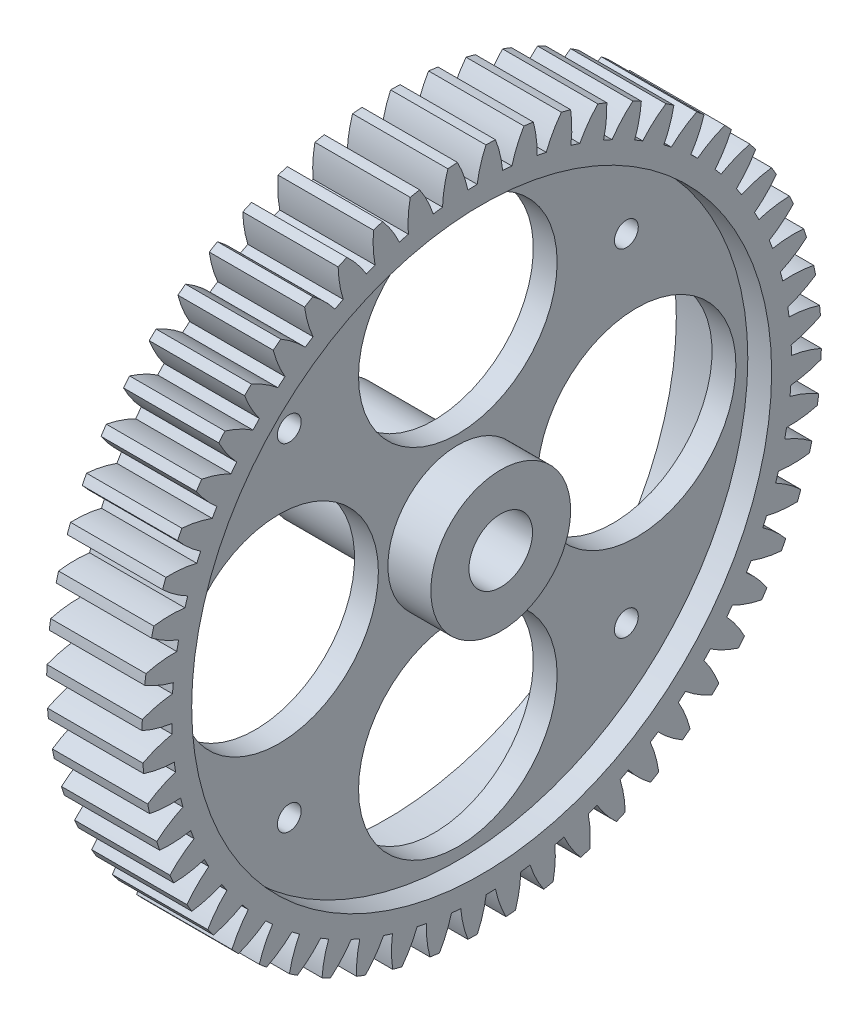
from build123d import *

# Parameters (mm, degrees)
SKETCH1_R           = 39
SKETCH1_R_2         = 4
SKETCH1_R_3         = 12.5
SKETCH1_R_4         = 1.5
BOSS_EXTRUDE1_DEPTH = 12
SKETCH4_R           = 36.5
CUT_EXTRUDE1_DEPTH  = 3
SKETCH5_R           = 36.5
CUT_EXTRUDE2_DEPTH  = 6
SKETCH6_R           = 8.8
SKETCH6_R_2         = 4
BOSS_EXTRUDE2_DEPTH = 5.4
SKETCH7_R           = 7.2
SKETCH7_R_2         = 4
BOSS_EXTRUDE3_DEPTH = 13.5


with BuildPart() as part:
    # Sketch1 → Boss-Extrude1 (new body)
    with BuildSketch(Plane(origin=(0, 0, 0), x_dir=(0, 0, -1), z_dir=(1, 0, 0))):
        Circle(SKETCH1_R)
        Circle(SKETCH1_R_2, mode=Mode.SUBTRACT)
        with Locations((0, 22.5)):
            Circle(SKETCH1_R_3, mode=Mode.SUBTRACT)
        with Locations((22.5, 0)):
            Circle(SKETCH1_R_3, mode=Mode.SUBTRACT)
        with Locations((0, -22.5)):
            Circle(SKETCH1_R_3, mode=Mode.SUBTRACT)
        with Locations((-22.5, 0)):
            Circle(SKETCH1_R_3, mode=Mode.SUBTRACT)
        with Locations((21.213203436, -21.213203436)):
            Circle(SKETCH1_R_4, mode=Mode.SUBTRACT)
        with Locations((-21.213203436, -21.213203436)):
            Circle(SKETCH1_R_4, mode=Mode.SUBTRACT)
        with Locations((-21.213203436, 21.213203436)):
            Circle(SKETCH1_R_4, mode=Mode.SUBTRACT)
        with Locations((21.213203436, 21.213203436)):
            Circle(SKETCH1_R_4, mode=Mode.SUBTRACT)
        with BuildLine():
            ThreePointArc((-0.563449374, 38.995929593), (1.036858006, 38.986214557), (2.635419512, 38.910854064))
            ThreePointArc((2.635419512, 38.910854064), (2.319554532, 40.844402901), (1.736231861, 42.714728127))
            ThreePointArc((1.736231861, 42.714728127), (1.136555891, 42.734889034), (0.536656028, 42.74663145))
            ThreePointArc((0.536656028, 42.74663145), (-0.145256199, 40.909955783), (-0.563449374, 38.995929593))
        make_face()
        with BuildLine():
            ThreePointArc((5.319385843, 42.417763192), (4.436118908, 40.668986102), (3.806252304, 38.813817686))
            ThreePointArc((3.806252304, 38.813817686), (5.395409549, 38.624986159), (6.975481938, 38.371117416))
            ThreePointArc((6.975481938, 38.371117416), (6.878091832, 40.32787416), (6.507846956, 42.251750591))
            ThreePointArc((6.507846956, 42.251750591), (5.914198928, 42.338927136), (5.319385843, 42.417763192))
        make_face()
        with BuildLine():
            ThreePointArc((10.035221295, 41.555466952), (8.961707246, 39.916580324), (8.128088151, 38.143599502))
            ThreePointArc((8.128088151, 38.143599502), (9.686110686, 37.77802615), (11.22782363, 37.348841703))
            ThreePointArc((11.22782363, 37.348841703), (11.350133137, 39.304199003), (11.197622099, 41.257432777))
            ThreePointArc((11.197622099, 41.257432777), (10.617467482, 41.410528664), (10.035221295, 41.555466952))
        make_face()
        with BuildLine():
            ThreePointArc((14.624858016, 40.170586603), (13.374596916, 38.662200388), (12.347708574, 36.993703423))
            ThreePointArc((12.347708574, 36.993703423), (13.855003361, 36.455985542), (15.338968926, 35.856882635))
            ThreePointArc((15.338968926, 35.856882635), (15.679439933, 37.786250739), (15.746580648, 39.744278807))
            ThreePointArc((15.746580648, 39.744278807), (15.187215222, 39.961368768), (14.624858016, 40.170586603))
        make_face()
        with BuildLine():
            ThreePointArc((19.030578662, 38.28053782), (17.619293269, 36.921620851), (16.412049397, 35.378590059))
            ThreePointArc((16.412049397, 35.378590059), (17.84966133, 34.675489765), (19.257217788, 33.914002463))
            ThreePointArc((19.257217788, 33.914002463), (19.811568673, 35.793118448), (20.097516809, 37.731317471))
            ThreePointArc((20.097516809, 37.731317471), (19.565974919, 38.009671473), (19.030578662, 38.28053782))
        make_face()
        with BuildLine():
            ThreePointArc((23.19697874, 35.909089063), (21.642416787, 34.716730508), (20.269999177, 33.318570398))
            ThreePointArc((20.269999177, 33.318570398), (21.619849451, 32.458929584), (22.933295963, 31.544634033))
            ThreePointArc((22.933295963, 31.544634033), (23.694555443, 33.349866925), (24.195715035, 35.243862926))
            ThreePointArc((24.195715035, 35.243862926), (23.698681129, 35.579980505), (23.19697874, 35.909089063))
        make_face()
        with BuildLine():
            ThreePointArc((27.071663351, 33.086062676), (25.393374356, 32.075257136), (23.873041955, 30.839550382))
            ThreePointArc((23.873041955, 30.839550382), (25.118155421, 29.83417953), (26.320974635, 28.778573527))
            ThreePointArc((26.320974635, 28.778573527), (27.27956943, 30.487221475), (27.989638105, 32.313196356))
            ThreePointArc((27.989638105, 32.313196356), (27.533362673, 32.702850639), (27.071663351, 33.086062676))
        make_face()
        with BuildLine():
            ThreePointArc((30.605906088, 29.846959855), (28.824995509, 29.030418795), (27.17586738, 27.972705127))
            ThreePointArc((27.17586738, 27.972705127), (28.300586013, 26.834247359), (29.377651779, 25.650605762))
            ThreePointArc((29.377651779, 25.650605762), (30.521527004, 27.241181526), (31.431575237, 28.976172593))
            ThreePointArc((31.431575237, 28.976172593), (31.021796207, 29.414463451), (30.605906088, 29.846959855))
        make_face()
        with BuildLine():
            ThreePointArc((33.755261797, 26.232514195), (31.894125619, 25.620506094), (30.136940505, 24.754086875))
            ThreePointArc((30.136940505, 24.754086875), (31.127120316, 23.496858957), (32.064887907, 22.200066746))
            ThreePointArc((32.064887907, 22.200066746), (33.379658666, 23.652567913), (34.478242073, 25.274756647))
            ThreePointArc((34.478242073, 25.274756647), (34.120112654, 25.756172319), (33.755261797, 26.232514195))
        make_face()
        with BuildLine():
            ThreePointArc((36.480125505, 22.288179449), (34.562168594, 21.888400664), (32.719024117, 21.224171617))
            ThreePointArc((32.719024117, 21.224171617), (33.56221302, 19.863983921), (34.348889464, 18.47034901))
            ThreePointArc((34.348889464, 18.47034901), (35.818021753, 19.766509536), (37.09132501, 21.255495971))
            ThreePointArc((37.09132501, 21.255495971), (36.789348887, 21.773982375), (36.480125505, 22.288179449))
        make_face()
        with BuildLine():
            ThreePointArc((38.746230468, 18.063557914), (36.795572245, 17.881035895), (34.889647017, 17.427350087))
            ThreePointArc((34.889647017, 17.427350087), (35.575241422, 15.981307762), (36.200933807, 14.508355919))
            ThreePointArc((36.200933807, 14.508355919), (37.805952435, 15.631875832), (39.237963015, 16.968935101))
            ThreePointArc((39.237963015, 16.968935101), (38.995937712, 17.51797197), (38.746230468, 18.063557914))
        make_face()
        with BuildLine():
            ThreePointArc((40.525079102, 13.611776658), (38.566250226, 13.648806725), (36.621512362, 13.411369518))
            ThreePointArc((36.621512362, 13.411369518), (37.140890522, 11.897657385), (37.597730404, 10.363911834))
            ThreePointArc((37.597730404, 10.363911834), (39.318451329, 11.30066222), (40.891160868, 12.468980027))
            ThreePointArc((40.891160868, 12.468980027), (40.712129995, 13.041662903), (40.525079102, 13.611776658))
        make_face()
        with BuildLine():
            ThreePointArc((41.794301353, 8.988819413), (39.851935234, 9.244935892), (37.89284094, 9.226733196))
            ThreePointArc((37.89284094, 9.226733196), (38.239471374, 7.664387064), (38.521713725, 6.089135544))
            ThreePointArc((38.521713725, 6.089135544), (40.336497885, 6.827336223), (42.030128647, 7.812220294))
            ThreePointArc((42.030128647, 7.812220294), (41.916343621, 8.401347358), (41.794301353, 8.988819413))
        make_face()
        with BuildLine():
            ThreePointArc((42.537936015, 4.252822548), (40.636459034, 4.724804625), (38.687645058, 4.92606535))
            ThreePointArc((38.687645058, 4.92606535), (38.857168686, 3.334732628), (38.961264146, 1.737784842))
            ThreePointArc((38.961264146, 1.737784842), (40.847289576, 2.268152513), (42.640543172, 3.057217358))
            ThreePointArc((42.640543172, 3.057217358), (42.593434906, 3.655379996), (42.537936015, 4.252822548))
        make_face()
        with BuildLine():
            ThreePointArc((42.74663145, -0.536656028), (40.909955783, 0.145256199), (38.995929593, 0.563449374))
            ThreePointArc((38.995929593, 0.563449374), (38.986214557, -1.036858006), (38.910854064, -2.635419512))
            ThreePointArc((38.910854064, -2.635419512), (40.844402901, -2.319554532), (42.714728127, -1.736231861))
            ThreePointArc((42.714728127, -1.736231861), (42.734889034, -1.136555891), (42.74663145, -0.536656028))
        make_face()
        with BuildLine():
            ThreePointArc((42.417763192, -5.319385843), (40.668986102, -4.436118908), (38.813817686, -3.806252304))
            ThreePointArc((38.813817686, -3.806252304), (38.624986159, -5.395409549), (38.371117416, -6.975481938))
            ThreePointArc((38.371117416, -6.975481938), (40.32787416, -6.878091832), (42.251750591, -6.507846956))
            ThreePointArc((42.251750591, -6.507846956), (42.338927136, -5.914198928), (42.417763192, -5.319385843))
        make_face()
        with BuildLine():
            ThreePointArc((41.555466952, -10.035221295), (39.916580324, -8.961707246), (38.143599502, -8.128088151))
            ThreePointArc((38.143599502, -8.128088151), (37.77802615, -9.686110686), (37.348841703, -11.22782363))
            ThreePointArc((37.348841703, -11.22782363), (39.304199003, -11.350133137), (41.257432777, -11.197622099))
            ThreePointArc((41.257432777, -11.197622099), (41.410528664, -10.617467482), (41.555466952, -10.035221295))
        make_face()
        with BuildLine():
            ThreePointArc((40.170586603, -14.624858016), (38.662200388, -13.374596916), (36.993703423, -12.347708574))
            ThreePointArc((36.993703423, -12.347708574), (36.455985542, -13.855003361), (35.856882635, -15.338968926))
            ThreePointArc((35.856882635, -15.338968926), (37.786250739, -15.679439933), (39.744278807, -15.746580648))
            ThreePointArc((39.744278807, -15.746580648), (39.961368768, -15.187215222), (40.170586603, -14.624858016))
        make_face()
        with BuildLine():
            ThreePointArc((38.28053782, -19.030578662), (36.921620851, -17.619293269), (35.378590059, -16.412049397))
            ThreePointArc((35.378590059, -16.412049397), (34.675489765, -17.84966133), (33.914002463, -19.257217788))
            ThreePointArc((33.914002463, -19.257217788), (35.793118448, -19.811568673), (37.731317471, -20.097516809))
            ThreePointArc((37.731317471, -20.097516809), (38.009671473, -19.565974919), (38.28053782, -19.030578662))
        make_face()
        with BuildLine():
            ThreePointArc((35.909089063, -23.19697874), (34.716730508, -21.642416787), (33.318570398, -20.269999177))
            ThreePointArc((33.318570398, -20.269999177), (32.458929584, -21.619849451), (31.544634033, -22.933295963))
            ThreePointArc((31.544634033, -22.933295963), (33.349866925, -23.694555443), (35.243862926, -24.195715035))
            ThreePointArc((35.243862926, -24.195715035), (35.579980505, -23.698681129), (35.909089063, -23.19697874))
        make_face()
        with BuildLine():
            ThreePointArc((33.086062676, -27.071663351), (32.075257136, -25.393374356), (30.839550382, -23.873041955))
            ThreePointArc((30.839550382, -23.873041955), (29.83417953, -25.118155421), (28.778573527, -26.320974635))
            ThreePointArc((28.778573527, -26.320974635), (30.487221475, -27.27956943), (32.313196356, -27.989638105))
            ThreePointArc((32.313196356, -27.989638105), (32.702850639, -27.533362673), (33.086062676, -27.071663351))
        make_face()
        with BuildLine():
            ThreePointArc((29.846959855, -30.605906088), (29.030418795, -28.824995509), (27.972705127, -27.17586738))
            ThreePointArc((27.972705127, -27.17586738), (26.834247359, -28.300586013), (25.650605762, -29.377651779))
            ThreePointArc((25.650605762, -29.377651779), (27.241181526, -30.521527004), (28.976172593, -31.431575237))
            ThreePointArc((28.976172593, -31.431575237), (29.414463451, -31.021796207), (29.846959855, -30.605906088))
        make_face()
        with BuildLine():
            ThreePointArc((26.232514195, -33.755261797), (25.620506094, -31.894125619), (24.754086875, -30.136940505))
            ThreePointArc((24.754086875, -30.136940505), (23.496858957, -31.127120316), (22.200066746, -32.064887907))
            ThreePointArc((22.200066746, -32.064887907), (23.652567913, -33.379658666), (25.274756647, -34.478242073))
            ThreePointArc((25.274756647, -34.478242073), (25.756172319, -34.120112654), (26.232514195, -33.755261797))
        make_face()
        with BuildLine():
            ThreePointArc((22.288179449, -36.480125505), (21.888400664, -34.562168594), (21.224171617, -32.719024117))
            ThreePointArc((21.224171617, -32.719024117), (19.863983921, -33.56221302), (18.47034901, -34.348889464))
            ThreePointArc((18.47034901, -34.348889464), (19.766509536, -35.818021753), (21.255495971, -37.09132501))
            ThreePointArc((21.255495971, -37.09132501), (21.773982375, -36.789348887), (22.288179449, -36.480125505))
        make_face()
        with BuildLine():
            ThreePointArc((18.063557914, -38.746230468), (17.881035895, -36.795572245), (17.427350087, -34.889647017))
            ThreePointArc((17.427350087, -34.889647017), (15.981307762, -35.575241422), (14.508355919, -36.200933807))
            ThreePointArc((14.508355919, -36.200933807), (15.631875832, -37.805952435), (16.968935101, -39.237963015))
            ThreePointArc((16.968935101, -39.237963015), (17.51797197, -38.995937712), (18.063557914, -38.746230468))
        make_face()
        with BuildLine():
            ThreePointArc((13.611776658, -40.525079102), (13.648806725, -38.566250226), (13.411369518, -36.621512362))
            ThreePointArc((13.411369518, -36.621512362), (11.897657385, -37.140890522), (10.363911834, -37.597730404))
            ThreePointArc((10.363911834, -37.597730404), (11.30066222, -39.318451329), (12.468980027, -40.891160868))
            ThreePointArc((12.468980027, -40.891160868), (13.041662903, -40.712129995), (13.611776658, -40.525079102))
        make_face()
        with BuildLine():
            ThreePointArc((8.988819413, -41.794301353), (9.244935892, -39.851935234), (9.226733196, -37.89284094))
            ThreePointArc((9.226733196, -37.89284094), (7.664387064, -38.239471374), (6.089135544, -38.521713725))
            ThreePointArc((6.089135544, -38.521713725), (6.827336223, -40.336497885), (7.812220294, -42.030128647))
            ThreePointArc((7.812220294, -42.030128647), (8.401347358, -41.916343621), (8.988819413, -41.794301353))
        make_face()
        with BuildLine():
            ThreePointArc((4.252822548, -42.537936015), (4.724804625, -40.636459034), (4.92606535, -38.687645058))
            ThreePointArc((4.92606535, -38.687645058), (3.334732628, -38.857168686), (1.737784842, -38.961264146))
            ThreePointArc((1.737784842, -38.961264146), (2.268152513, -40.847289576), (3.057217358, -42.640543172))
            ThreePointArc((3.057217358, -42.640543172), (3.655379996, -42.593434906), (4.252822548, -42.537936015))
        make_face()
        with BuildLine():
            ThreePointArc((-0.536656028, -42.74663145), (0.145256199, -40.909955783), (0.563449374, -38.995929593))
            ThreePointArc((0.563449374, -38.995929593), (-1.036858006, -38.986214557), (-2.635419512, -38.910854064))
            ThreePointArc((-2.635419512, -38.910854064), (-2.319554532, -40.844402901), (-1.736231861, -42.714728127))
            ThreePointArc((-1.736231861, -42.714728127), (-1.136555891, -42.734889034), (-0.536656028, -42.74663145))
        make_face()
        with BuildLine():
            ThreePointArc((-5.319385843, -42.417763192), (-4.436118908, -40.668986102), (-3.806252304, -38.813817686))
            ThreePointArc((-3.806252304, -38.813817686), (-5.395409549, -38.624986159), (-6.975481938, -38.371117416))
            ThreePointArc((-6.975481938, -38.371117416), (-6.878091832, -40.32787416), (-6.507846956, -42.251750591))
            ThreePointArc((-6.507846956, -42.251750591), (-5.914198928, -42.338927136), (-5.319385843, -42.417763192))
        make_face()
        with BuildLine():
            ThreePointArc((-10.035221295, -41.555466952), (-8.961707246, -39.916580324), (-8.128088151, -38.143599502))
            ThreePointArc((-8.128088151, -38.143599502), (-9.686110686, -37.77802615), (-11.22782363, -37.348841703))
            ThreePointArc((-11.22782363, -37.348841703), (-11.350133137, -39.304199003), (-11.197622099, -41.257432777))
            ThreePointArc((-11.197622099, -41.257432777), (-10.617467482, -41.410528664), (-10.035221295, -41.555466952))
        make_face()
        with BuildLine():
            ThreePointArc((-14.624858016, -40.170586603), (-13.374596916, -38.662200388), (-12.347708574, -36.993703423))
            ThreePointArc((-12.347708574, -36.993703423), (-13.855003361, -36.455985542), (-15.338968926, -35.856882635))
            ThreePointArc((-15.338968926, -35.856882635), (-15.679439933, -37.786250739), (-15.746580648, -39.744278807))
            ThreePointArc((-15.746580648, -39.744278807), (-15.187215222, -39.961368768), (-14.624858016, -40.170586603))
        make_face()
        with BuildLine():
            ThreePointArc((-19.030578662, -38.28053782), (-17.619293269, -36.921620851), (-16.412049397, -35.378590059))
            ThreePointArc((-16.412049397, -35.378590059), (-17.84966133, -34.675489765), (-19.257217788, -33.914002463))
            ThreePointArc((-19.257217788, -33.914002463), (-19.811568673, -35.793118448), (-20.097516809, -37.731317471))
            ThreePointArc((-20.097516809, -37.731317471), (-19.565974919, -38.009671473), (-19.030578662, -38.28053782))
        make_face()
        with BuildLine():
            ThreePointArc((-23.19697874, -35.909089063), (-21.642416787, -34.716730508), (-20.269999177, -33.318570398))
            ThreePointArc((-20.269999177, -33.318570398), (-21.619849451, -32.458929584), (-22.933295963, -31.544634033))
            ThreePointArc((-22.933295963, -31.544634033), (-23.694555443, -33.349866925), (-24.195715035, -35.243862926))
            ThreePointArc((-24.195715035, -35.243862926), (-23.698681129, -35.579980505), (-23.19697874, -35.909089063))
        make_face()
        with BuildLine():
            ThreePointArc((-27.071663351, -33.086062676), (-25.393374356, -32.075257136), (-23.873041955, -30.839550382))
            ThreePointArc((-23.873041955, -30.839550382), (-25.118155421, -29.83417953), (-26.320974635, -28.778573527))
            ThreePointArc((-26.320974635, -28.778573527), (-27.27956943, -30.487221475), (-27.989638105, -32.313196356))
            ThreePointArc((-27.989638105, -32.313196356), (-27.533362673, -32.702850639), (-27.071663351, -33.086062676))
        make_face()
        with BuildLine():
            ThreePointArc((-30.605906088, -29.846959855), (-28.824995509, -29.030418795), (-27.17586738, -27.972705127))
            ThreePointArc((-27.17586738, -27.972705127), (-28.300586013, -26.834247359), (-29.377651779, -25.650605762))
            ThreePointArc((-29.377651779, -25.650605762), (-30.521527004, -27.241181526), (-31.431575237, -28.976172593))
            ThreePointArc((-31.431575237, -28.976172593), (-31.021796207, -29.414463451), (-30.605906088, -29.846959855))
        make_face()
        with BuildLine():
            ThreePointArc((-33.755261797, -26.232514195), (-31.894125619, -25.620506094), (-30.136940505, -24.754086875))
            ThreePointArc((-30.136940505, -24.754086875), (-31.127120316, -23.496858957), (-32.064887907, -22.200066746))
            ThreePointArc((-32.064887907, -22.200066746), (-33.379658666, -23.652567913), (-34.478242073, -25.274756647))
            ThreePointArc((-34.478242073, -25.274756647), (-34.120112654, -25.756172319), (-33.755261797, -26.232514195))
        make_face()
        with BuildLine():
            ThreePointArc((-36.480125505, -22.288179449), (-34.562168594, -21.888400664), (-32.719024117, -21.224171617))
            ThreePointArc((-32.719024117, -21.224171617), (-33.56221302, -19.863983921), (-34.348889464, -18.47034901))
            ThreePointArc((-34.348889464, -18.47034901), (-35.818021753, -19.766509536), (-37.09132501, -21.255495971))
            ThreePointArc((-37.09132501, -21.255495971), (-36.789348887, -21.773982375), (-36.480125505, -22.288179449))
        make_face()
        with BuildLine():
            ThreePointArc((-38.746230468, -18.063557914), (-36.795572245, -17.881035895), (-34.889647017, -17.427350087))
            ThreePointArc((-34.889647017, -17.427350087), (-35.575241422, -15.981307762), (-36.200933807, -14.508355919))
            ThreePointArc((-36.200933807, -14.508355919), (-37.805952435, -15.631875832), (-39.237963015, -16.968935101))
            ThreePointArc((-39.237963015, -16.968935101), (-38.995937712, -17.51797197), (-38.746230468, -18.063557914))
        make_face()
        with BuildLine():
            ThreePointArc((-40.525079102, -13.611776658), (-38.566250226, -13.648806725), (-36.621512362, -13.411369518))
            ThreePointArc((-36.621512362, -13.411369518), (-37.140890522, -11.897657385), (-37.597730404, -10.363911834))
            ThreePointArc((-37.597730404, -10.363911834), (-39.318451329, -11.30066222), (-40.891160868, -12.468980027))
            ThreePointArc((-40.891160868, -12.468980027), (-40.712129995, -13.041662903), (-40.525079102, -13.611776658))
        make_face()
        with BuildLine():
            ThreePointArc((-41.794301353, -8.988819413), (-39.851935234, -9.244935892), (-37.89284094, -9.226733196))
            ThreePointArc((-37.89284094, -9.226733196), (-38.239471374, -7.664387064), (-38.521713725, -6.089135544))
            ThreePointArc((-38.521713725, -6.089135544), (-40.336497885, -6.827336223), (-42.030128647, -7.812220294))
            ThreePointArc((-42.030128647, -7.812220294), (-41.916343621, -8.401347358), (-41.794301353, -8.988819413))
        make_face()
        with BuildLine():
            ThreePointArc((-42.537936015, -4.252822548), (-40.636459034, -4.724804625), (-38.687645058, -4.92606535))
            ThreePointArc((-38.687645058, -4.92606535), (-38.857168686, -3.334732628), (-38.961264146, -1.737784842))
            ThreePointArc((-38.961264146, -1.737784842), (-40.847289576, -2.268152513), (-42.640543172, -3.057217358))
            ThreePointArc((-42.640543172, -3.057217358), (-42.593434906, -3.655379996), (-42.537936015, -4.252822548))
        make_face()
        with BuildLine():
            ThreePointArc((-42.74663145, 0.536656028), (-40.909955783, -0.145256199), (-38.995929593, -0.563449374))
            ThreePointArc((-38.995929593, -0.563449374), (-38.986214557, 1.036858006), (-38.910854064, 2.635419512))
            ThreePointArc((-38.910854064, 2.635419512), (-40.844402901, 2.319554532), (-42.714728127, 1.736231861))
            ThreePointArc((-42.714728127, 1.736231861), (-42.734889034, 1.136555891), (-42.74663145, 0.536656028))
        make_face()
        with BuildLine():
            ThreePointArc((-42.417763192, 5.319385843), (-40.668986102, 4.436118908), (-38.813817686, 3.806252304))
            ThreePointArc((-38.813817686, 3.806252304), (-38.624986159, 5.395409549), (-38.371117416, 6.975481938))
            ThreePointArc((-38.371117416, 6.975481938), (-40.32787416, 6.878091832), (-42.251750591, 6.507846956))
            ThreePointArc((-42.251750591, 6.507846956), (-42.338927136, 5.914198928), (-42.417763192, 5.319385843))
        make_face()
        with BuildLine():
            ThreePointArc((-41.555466952, 10.035221295), (-39.916580324, 8.961707246), (-38.143599502, 8.128088151))
            ThreePointArc((-38.143599502, 8.128088151), (-37.77802615, 9.686110686), (-37.348841703, 11.22782363))
            ThreePointArc((-37.348841703, 11.22782363), (-39.304199003, 11.350133137), (-41.257432777, 11.197622099))
            ThreePointArc((-41.257432777, 11.197622099), (-41.410528664, 10.617467482), (-41.555466952, 10.035221295))
        make_face()
        with BuildLine():
            ThreePointArc((-40.170586603, 14.624858016), (-38.662200388, 13.374596916), (-36.993703423, 12.347708574))
            ThreePointArc((-36.993703423, 12.347708574), (-36.455985542, 13.855003361), (-35.856882635, 15.338968926))
            ThreePointArc((-35.856882635, 15.338968926), (-37.786250739, 15.679439933), (-39.744278807, 15.746580648))
            ThreePointArc((-39.744278807, 15.746580648), (-39.961368768, 15.187215222), (-40.170586603, 14.624858016))
        make_face()
        with BuildLine():
            ThreePointArc((-38.28053782, 19.030578662), (-36.921620851, 17.619293269), (-35.378590059, 16.412049397))
            ThreePointArc((-35.378590059, 16.412049397), (-34.675489765, 17.84966133), (-33.914002463, 19.257217788))
            ThreePointArc((-33.914002463, 19.257217788), (-35.793118448, 19.811568673), (-37.731317471, 20.097516809))
            ThreePointArc((-37.731317471, 20.097516809), (-38.009671473, 19.565974919), (-38.28053782, 19.030578662))
        make_face()
        with BuildLine():
            ThreePointArc((-35.909089063, 23.19697874), (-34.716730508, 21.642416787), (-33.318570398, 20.269999177))
            ThreePointArc((-33.318570398, 20.269999177), (-32.458929584, 21.619849451), (-31.544634033, 22.933295963))
            ThreePointArc((-31.544634033, 22.933295963), (-33.349866925, 23.694555443), (-35.243862926, 24.195715035))
            ThreePointArc((-35.243862926, 24.195715035), (-35.579980505, 23.698681129), (-35.909089063, 23.19697874))
        make_face()
        with BuildLine():
            ThreePointArc((-33.086062676, 27.071663351), (-32.075257136, 25.393374356), (-30.839550382, 23.873041955))
            ThreePointArc((-30.839550382, 23.873041955), (-29.83417953, 25.118155421), (-28.778573527, 26.320974635))
            ThreePointArc((-28.778573527, 26.320974635), (-30.487221475, 27.27956943), (-32.313196356, 27.989638105))
            ThreePointArc((-32.313196356, 27.989638105), (-32.702850639, 27.533362673), (-33.086062676, 27.071663351))
        make_face()
        with BuildLine():
            ThreePointArc((-29.846959855, 30.605906088), (-29.030418795, 28.824995509), (-27.972705127, 27.17586738))
            ThreePointArc((-27.972705127, 27.17586738), (-26.834247359, 28.300586013), (-25.650605762, 29.377651779))
            ThreePointArc((-25.650605762, 29.377651779), (-27.241181526, 30.521527004), (-28.976172593, 31.431575237))
            ThreePointArc((-28.976172593, 31.431575237), (-29.414463451, 31.021796207), (-29.846959855, 30.605906088))
        make_face()
        with BuildLine():
            ThreePointArc((-26.232514195, 33.755261797), (-25.620506094, 31.894125619), (-24.754086875, 30.136940505))
            ThreePointArc((-24.754086875, 30.136940505), (-23.496858957, 31.127120316), (-22.200066746, 32.064887907))
            ThreePointArc((-22.200066746, 32.064887907), (-23.652567913, 33.379658666), (-25.274756647, 34.478242073))
            ThreePointArc((-25.274756647, 34.478242073), (-25.756172319, 34.120112654), (-26.232514195, 33.755261797))
        make_face()
        with BuildLine():
            ThreePointArc((-22.288179449, 36.480125505), (-21.888400664, 34.562168594), (-21.224171617, 32.719024117))
            ThreePointArc((-21.224171617, 32.719024117), (-19.863983921, 33.56221302), (-18.47034901, 34.348889464))
            ThreePointArc((-18.47034901, 34.348889464), (-19.766509536, 35.818021753), (-21.255495971, 37.09132501))
            ThreePointArc((-21.255495971, 37.09132501), (-21.773982375, 36.789348887), (-22.288179449, 36.480125505))
        make_face()
        with BuildLine():
            ThreePointArc((-18.063557914, 38.746230468), (-17.881035895, 36.795572245), (-17.427350087, 34.889647017))
            ThreePointArc((-17.427350087, 34.889647017), (-15.981307762, 35.575241422), (-14.508355919, 36.200933807))
            ThreePointArc((-14.508355919, 36.200933807), (-15.631875832, 37.805952435), (-16.968935101, 39.237963015))
            ThreePointArc((-16.968935101, 39.237963015), (-17.51797197, 38.995937712), (-18.063557914, 38.746230468))
        make_face()
        with BuildLine():
            ThreePointArc((-13.611776658, 40.525079102), (-13.648806725, 38.566250226), (-13.411369518, 36.621512362))
            ThreePointArc((-13.411369518, 36.621512362), (-11.897657385, 37.140890522), (-10.363911834, 37.597730404))
            ThreePointArc((-10.363911834, 37.597730404), (-11.30066222, 39.318451329), (-12.468980027, 40.891160868))
            ThreePointArc((-12.468980027, 40.891160868), (-13.041662903, 40.712129995), (-13.611776658, 40.525079102))
        make_face()
        with BuildLine():
            ThreePointArc((-8.988819413, 41.794301353), (-9.244935892, 39.851935234), (-9.226733196, 37.89284094))
            ThreePointArc((-9.226733196, 37.89284094), (-7.664387064, 38.239471374), (-6.089135544, 38.521713725))
            ThreePointArc((-6.089135544, 38.521713725), (-6.827336223, 40.336497885), (-7.812220294, 42.030128647))
            ThreePointArc((-7.812220294, 42.030128647), (-8.401347358, 41.916343621), (-8.988819413, 41.794301353))
        make_face()
        with BuildLine():
            ThreePointArc((-4.252822548, 42.537936015), (-4.724804625, 40.636459034), (-4.92606535, 38.687645058))
            ThreePointArc((-4.92606535, 38.687645058), (-3.334732628, 38.857168686), (-1.737784842, 38.961264146))
            ThreePointArc((-1.737784842, 38.961264146), (-2.268152513, 40.847289576), (-3.057217358, 42.640543172))
            ThreePointArc((-3.057217358, 42.640543172), (-3.655379996, 42.593434906), (-4.252822548, 42.537936015))
        make_face()
    extrude(amount=BOSS_EXTRUDE1_DEPTH)

    # Sketch4 → Cut-Extrude1 (cut)
    with BuildSketch(Plane(origin=(12, 0, 0), x_dir=(0, 0, -1), z_dir=(1, 0, 0))):
        Circle(SKETCH4_R)
    extrude(amount=-CUT_EXTRUDE1_DEPTH, mode=Mode.SUBTRACT)

    # Sketch5 → Cut-Extrude2 (cut)
    with BuildSketch(Plane.ZY):
        Circle(SKETCH5_R)
    extrude(amount=-CUT_EXTRUDE2_DEPTH, mode=Mode.SUBTRACT)

    # Sketch6 → Boss-Extrude2 (add)
    with BuildSketch(Plane(origin=(9, 0, 0), x_dir=(0, 0, -1), z_dir=(1, 0, 0))):
        Circle(SKETCH6_R)
        Circle(SKETCH6_R_2, mode=Mode.SUBTRACT)
    extrude(amount=BOSS_EXTRUDE2_DEPTH)

    # Sketch7 → Boss-Extrude3 (add)
    with BuildSketch(Plane.ZY.offset(-6)):
        Circle(SKETCH7_R)
        Circle(SKETCH7_R_2, mode=Mode.SUBTRACT)
    extrude(amount=BOSS_EXTRUDE3_DEPTH)


solid = part.part
